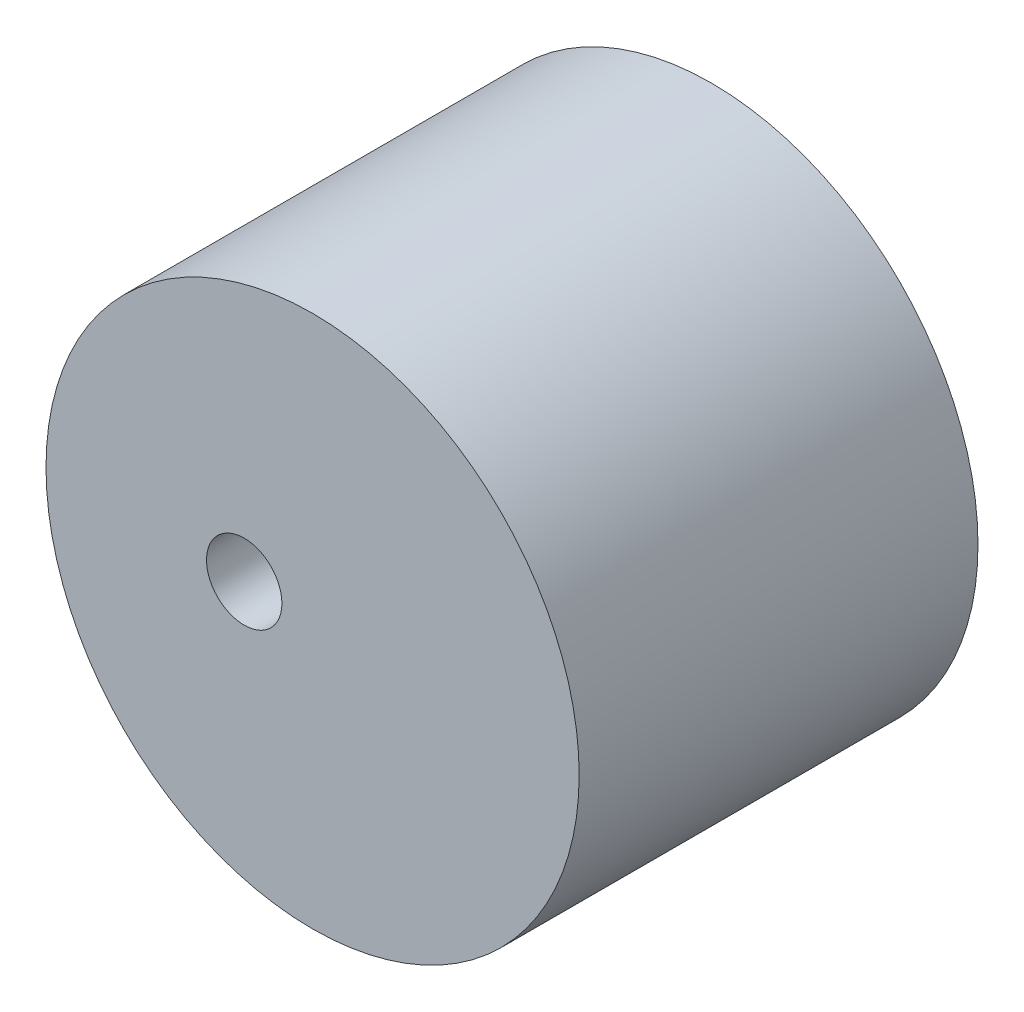
from build123d import *

# Parameters (mm, degrees)
SKETCH11_R           = 23.39375
SKETCH11_R_2         = 3.3085
BOSS_EXTRUDE13_DEPTH = 35


with BuildPart() as part:
    # Sketch11 → Boss-Extrude13 (new body)
    with BuildSketch(Plane.XY):
        Circle(SKETCH11_R)
        with Locations((-6, 0)):
            Circle(SKETCH11_R_2, mode=Mode.SUBTRACT)
    extrude(amount=BOSS_EXTRUDE13_DEPTH)


solid = part.part
